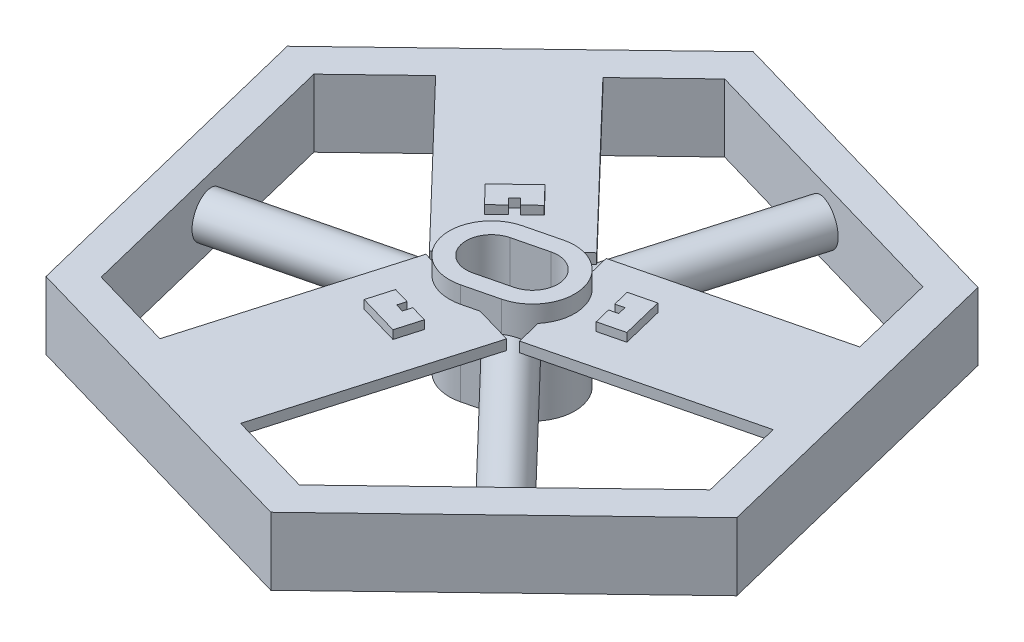
from build123d import *

# Parameters (mm, degrees)
BOSS_EXTRUDE5_DEPTH      = 40
BOSS_EXTRUDE9_DEPTH      = 10
BOSS_EXTRUDE9_DEPTH_BACK = 50
BOSS_EXTRUDE10_DEPTH     = 120
SKETCH5_R                = 12.5
BOSS_EXTRUDE11_DEPTH     = 127
BOSS_EXTRUDE12_DEPTH     = 127
SKETCH8_W                = 70
SKETCH8_H                = 6
BOSS_EXTRUDE14_DEPTH     = 127
SKETCH9_W                = 70
SKETCH9_H                = 6
BOSS_EXTRUDE15_DEPTH     = 127
SKETCH10_W               = 70
SKETCH10_H               = 6
BOSS_EXTRUDE16_DEPTH     = 124
EXTRUDE_THIN1_DEPTH      = 5


with BuildPart() as part:
    # Sketch1 → Boss-Extrude5 (new body)
    with BuildSketch(Plane(origin=(0, 0, 0), x_dir=(1, 0, 0), z_dir=(0, 1, 0))):
        Polygon((-140.670056302, -135.044197431), (46.616677458, -189.345941025), (187.28673376, -54.301743594), (140.670056302, 135.044197431), (-46.616677458, 189.345941025), (-187.28673376, 54.301743594), align=None)
        Polygon((165.106211473, -47.870743331), (124.010385559, 119.050801792), (-41.095825913, 166.921545124), (-165.106211473, 47.870743331), (-124.010385559, -119.050801792), (41.095825913, -166.921545124), align=None, mode=Mode.SUBTRACT)
    extrude(amount=BOSS_EXTRUDE5_DEPTH)



with BuildPart() as body_2:
    # Sketch3 → Boss-Extrude9 (new body, two sides)
    with BuildSketch(Plane.XZ) as boss_extrude9_sk:
        with BuildLine():
            Line((3.733551148, -26.665719488), (-15.686545368, -21.8845218))
            ThreePointArc((-15.686545368, -21.8845218), (-33.985168902, 8.367095954), (-3.733551148, 26.665719488))
            Line((-3.733551148, 26.665719488), (15.686545368, 21.8845218))
            ThreePointArc((15.686545368, 21.8845218), (33.985168902, -8.367095954), (3.733551148, -26.665719488))
        make_face()
        with BuildLine():
            Line((6.124149992, -16.955671231), (-13.295946524, -12.174473543))
            ThreePointArc((-13.295946524, -12.174473543), (-24.275120644, 5.97649711), (-6.124149992, 16.955671231))
            Line((-6.124149992, 16.955671231), (13.295946524, 12.174473543))
            ThreePointArc((13.295946524, 12.174473543), (24.275120644, -5.97649711), (6.124149992, -16.955671231))
        make_face(mode=Mode.SUBTRACT)
    extrude(amount=BOSS_EXTRUDE9_DEPTH)
    extrude(boss_extrude9_sk.sketch, amount=-BOSS_EXTRUDE9_DEPTH_BACK)


with BuildPart() as part_1:
    add(part.part)

    add(body_2.part)  # Boss-Extrude10 merges body 2
    # Sketch4 → Boss-Extrude10 (add)
    with BuildSketch(Plane(origin=(-144.558298516, 0, 35.590029231), x_dir=(-0.239059884, 0, -0.971004826), z_dir=(0.971004826, 0, -0.239059884))):
        with BuildLine():
            ThreePointArc((12.5, 20), (0, 32.5), (-12.5, 20))
            Line((-12.5, 20), (12.5, 20))
        make_face()
        with BuildLine():
            Line((12.5, 20), (-12.5, 20))
            ThreePointArc((-12.5, 20), (0, 7.5), (12.5, 20))
        make_face()
    extrude(amount=BOSS_EXTRUDE10_DEPTH)

    # Sketch5 → Boss-Extrude11 (add)
    with BuildSketch(Plane(origin=(41.457279823, 0, -142.986173458), x_dir=(0.960444789, 0, 0.27847048), z_dir=(-0.27847048, 0, 0.960444789))):
        with Locations((0, 20)):
            Circle(SKETCH5_R)
    extrude(amount=BOSS_EXTRUDE11_DEPTH)

    # Sketch6 → Boss-Extrude12 (add)
    with BuildSketch(Plane(origin=(103.101018693, 0, 107.396144227), x_dir=(-0.721384904, 0, 0.692534346), z_dir=(-0.692534346, 0, -0.721384904))):
        with BuildLine():
            ThreePointArc((-12.5, 20), (0, 7.5), (12.5, 20))
            Line((12.5, 20), (-12.5, 20))
        make_face()
        with BuildLine():
            Line((-12.5, 20), (12.5, 20))
            ThreePointArc((12.5, 20), (0, 32.5), (-12.5, 20))
        make_face()
    extrude(amount=BOSS_EXTRUDE12_DEPTH)

    # Sketch8 → Boss-Extrude14 (add)
    with BuildSketch(Plane(origin=(-103.101018693, 0, -107.396144227), x_dir=(0.721384904, 0, -0.692534346), z_dir=(0.692534346, 0, 0.721384904))):
        with Locations((0, 37)):
            Rectangle(SKETCH8_W, SKETCH8_H)
    extrude(amount=BOSS_EXTRUDE14_DEPTH)

    # Sketch9 → Boss-Extrude15 (add)
    with BuildSketch(Plane(origin=(-41.457279823, 0, 142.986173458), x_dir=(-0.960444789, 0, -0.27847048), z_dir=(0.27847048, 0, -0.960444789))):
        with Locations((0, 37)):
            Rectangle(SKETCH9_W, SKETCH9_H)
    extrude(amount=BOSS_EXTRUDE15_DEPTH)

    # Sketch10 → Boss-Extrude16 (add)
    with BuildSketch(Plane(origin=(144.558298516, 0, -35.590029231), x_dir=(0.239059884, 0, 0.971004826), z_dir=(-0.971004826, 0, 0.239059884))):
        with Locations((0, 37)):
            Rectangle(SKETCH10_W, SKETCH10_H)
    extrude(amount=BOSS_EXTRUDE16_DEPTH)

    # Sketch14 → Extrude-Thin1 (add)
    with BuildSketch(Plane(origin=(0, 40, 0), x_dir=(1, 0, 0), z_dir=(0, 1, 0))):
        Polygon((50.306594431, -0.487856845), (64.871666817, 3.098041421), (58.895169707, 27.373162065), (44.330097321, 23.787263799), (46.720696165, 14.077215541), (51.575720293, 15.272514963), (52.771019715, 10.417490835), (47.915995587, 9.222191413), align=None)
        Polygon((-25.575793637, -43.322860332), (-29.752850836, -57.72953216), (-5.741731123, -64.691294159), (-1.564673924, -50.284622331), (-11.169121809, -47.499917532), (-12.561474209, -52.302141474), (-17.363698151, -50.909789074), (-15.971345751, -46.107565132), align=None)
        Polygon((-24.730800794, 43.810717177), (-35.118815981, 54.631490739), (-53.153438584, 37.318132094), (-42.765423397, 26.497358532), (-35.551574356, 33.42270199), (-39.014246085, 37.029626511), (-35.407321564, 40.49229824), (-31.944649835, 36.885373719), align=None)
    extrude(amount=EXTRUDE_THIN1_DEPTH)


solid = part_1.part
